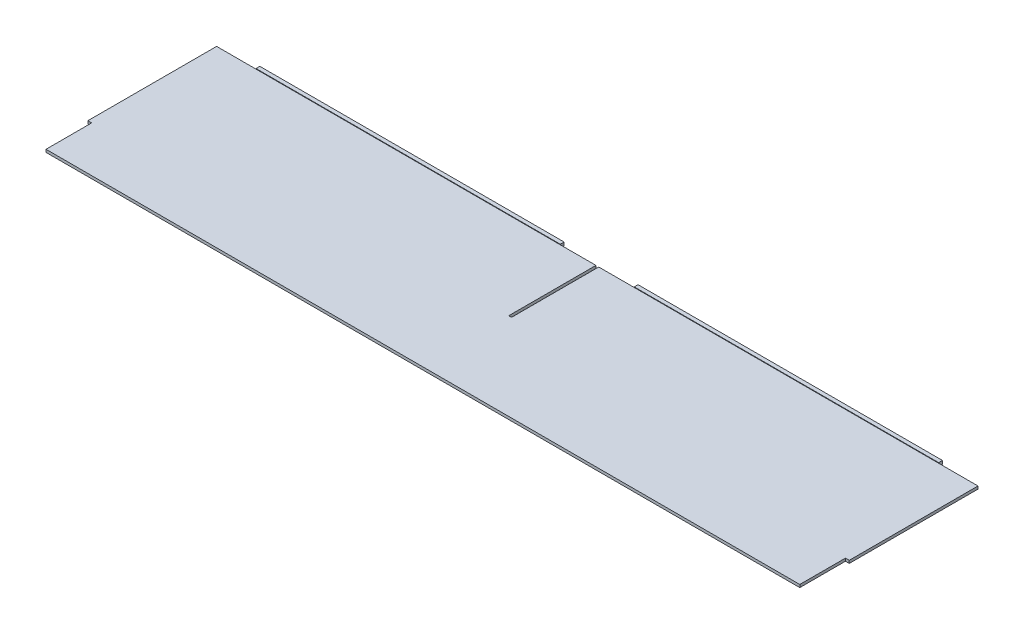
from build123d import *

# Parameters (mm, degrees)
SKETCH1_W           = 635.3556
SKETCH1_H           = 145.542
BOSS_EXTRUDE1_DEPTH = 1.143
SKETCH2_W           = 254
SKETCH2_H           = 2.7305
BOSS_EXTRUDE2_DEPTH = 3.175
SKETCH3_W           = 3.175
SKETCH3_H           = 38.1
CUT_EXTRUDE1_DEPTH  = 3.7305
SKETCH4_W           = 2.3368
SKETCH4_H           = 72.771
CUT_EXTRUDE2_DEPTH  = 3.7305


with BuildPart() as part:
    # Sketch1 → Boss-Extrude1 (new body, symmetric)
    with BuildSketch(Plane(origin=(0, 0, 0), x_dir=(1, 0, 0), z_dir=(0, 1, 0))):
        Rectangle(SKETCH1_W, SKETCH1_H)
    extrude(amount=BOSS_EXTRUDE1_DEPTH, both=True)

    # Sketch2 → Boss-Extrude2 (add)
    with BuildSketch(Plane(origin=(0, 0, -72.771), x_dir=(-1, 0, 0), z_dir=(0, 0, -1))):
        with Locations((-157.8229, 0.22225)):
            Rectangle(SKETCH2_W, SKETCH2_H)
        with Locations((157.8229, 0.22225)):
            Rectangle(SKETCH2_W, SKETCH2_H)
    extrude(amount=BOSS_EXTRUDE2_DEPTH)

    # Sketch3 → Cut-Extrude1 (cut, through all)
    with BuildSketch(Plane.XZ.offset(1.143)):
        with Locations((-316.0903, 53.721)):
            Rectangle(SKETCH3_W, SKETCH3_H)
    cut_extrude1 = extrude(amount=-CUT_EXTRUDE1_DEPTH, mode=Mode.SUBTRACT)

    # Mirror1: Cut-Extrude1 across plane
    add(cut_extrude1.mirror(Plane(origin=(0, 0, 0), x_dir=(0, 0, 1), z_dir=(1, 0, 0))), mode=Mode.SUBTRACT)

    # Sketch4 → Cut-Extrude2 (cut, through all)
    with BuildSketch(Plane.XZ.offset(1.143)):
        with Locations((0.0254, -36.3855)):
            Rectangle(SKETCH4_W, SKETCH4_H)
    extrude(amount=-CUT_EXTRUDE2_DEPTH, mode=Mode.SUBTRACT)


solid = part.part
